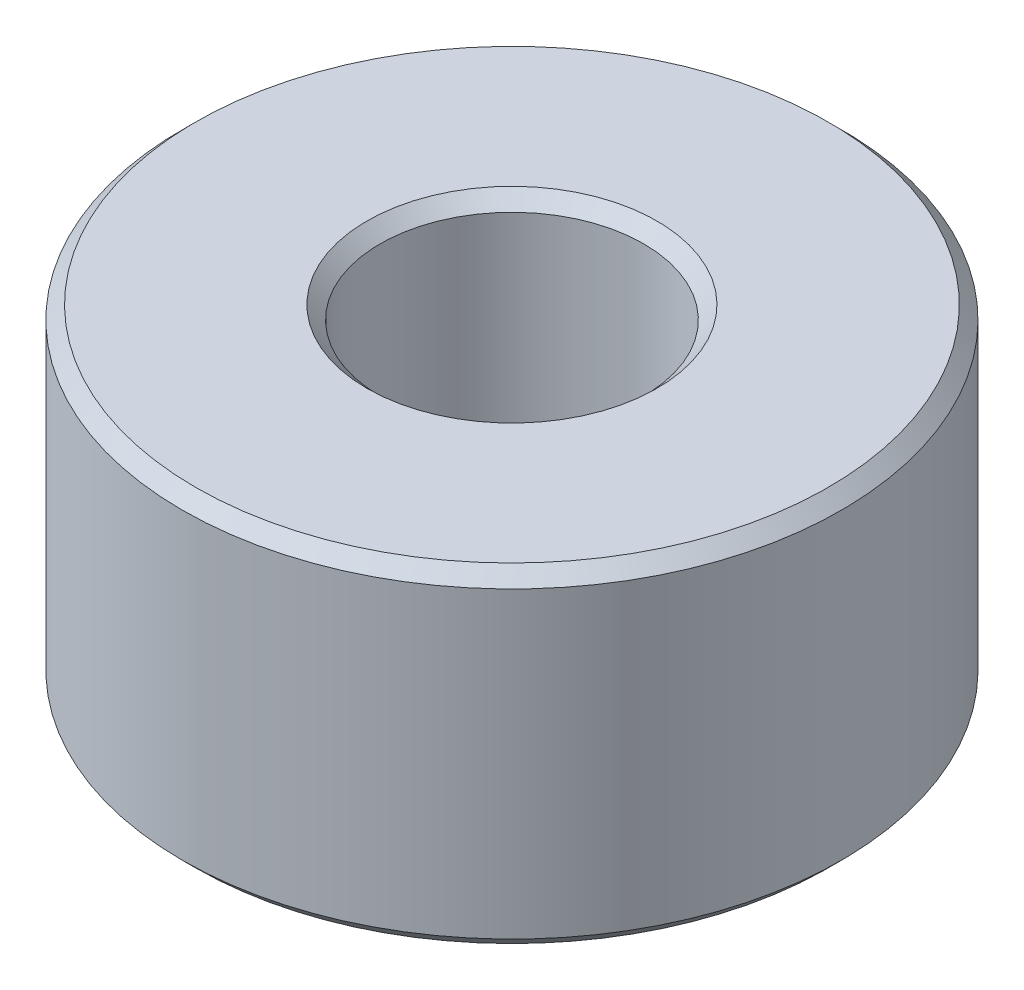
from build123d import *

# Parameters (mm, degrees)
SKETCH_1_R      = 2.5
SKETCH_1_R_2    = 1
EXTRUDE_1_DEPTH = 2.5
CHAMFER_1_SIZE  = 0.1


with BuildPart() as part:
    # 草图1 → 凸台-拉伸1 (new body)
    with BuildSketch(Plane(origin=(0, 0, 0), x_dir=(1, 0, 0), z_dir=(0, 1, 0))):
        Circle(SKETCH_1_R)
        Circle(SKETCH_1_R_2, mode=Mode.SUBTRACT)
    extrude(amount=EXTRUDE_1_DEPTH)

    # 倒角1
    chamfer_1_edges = [part.edges().sort_by_distance(p)[0] for p in [
        (-2.5, 0, 0),
        (-2.5, 2.5, 0),
        (-1, 0, 0),
        (-1, 2.5, 0),
    ]]
    chamfer(chamfer_1_edges, length=CHAMFER_1_SIZE)


solid = part.part
